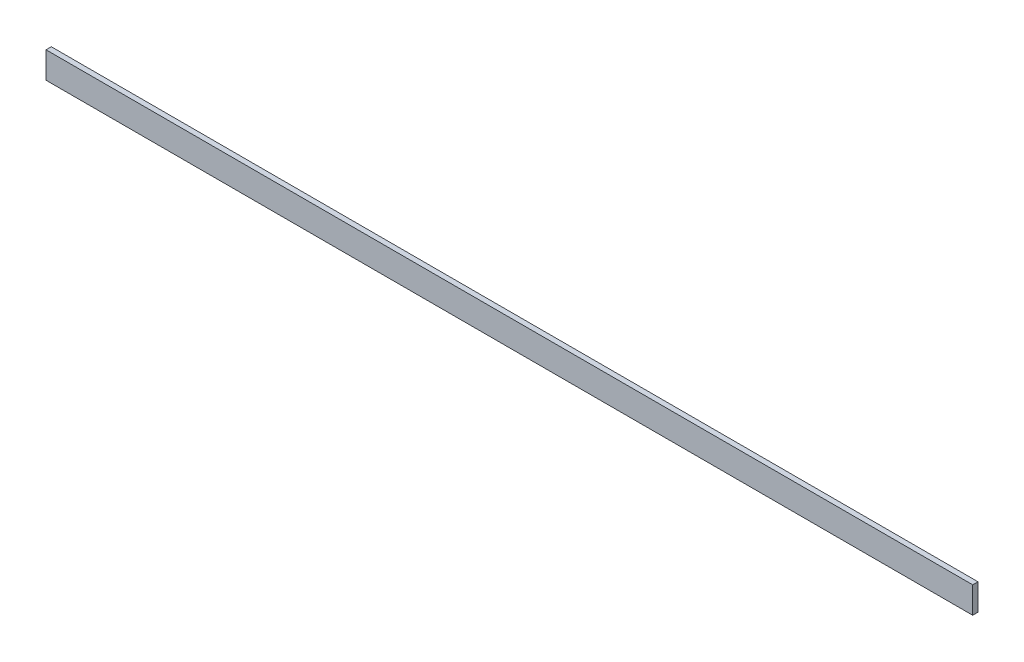
from build123d import *

# Parameters (mm, degrees)
SKETCH1_W           = 351.17191679
SKETCH1_H           = 10
BOSS_EXTRUDE1_DEPTH = 2


with BuildPart() as part:
    # Sketch1 → Boss-Extrude1 (new body)
    with BuildSketch(Plane.XY):
        with Locations((-1.541534381, -0.278971309)):
            Rectangle(SKETCH1_W, SKETCH1_H)
    extrude(amount=BOSS_EXTRUDE1_DEPTH)


solid = part.part
